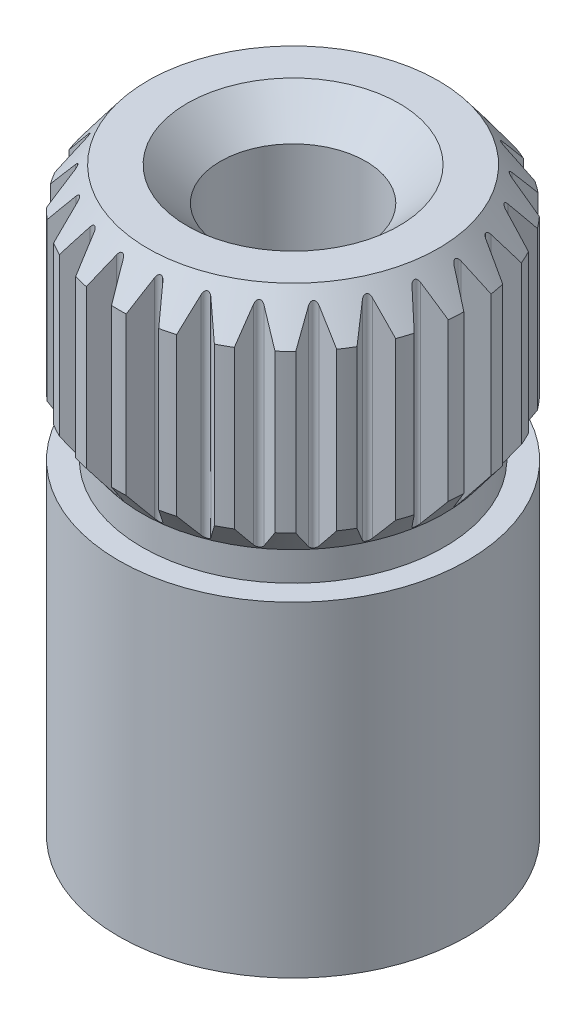
from build123d import *

# Parameters (mm, degrees)
ENL_V_MAT_EXTRU_2_REACH      = 12.863
R_P_TITION_CIRCULAIRE2_COUNT = 25
TROU_TARAUD_M31_D            = 2.5
TROU_TARAUD_M31_DEPTH        = 9
TROU_TARAUD_M31_TIP          = 0.751075774


with BuildPart() as part:
    # Esquisse5 → Révolution1 (revolve)
    with BuildSketch(Plane.XY):
        Polygon((-2.5, 44.2), (0, 44.2), (0, 34.2), (-3, 34.2), (-3, 39.8), (-2.6, 39.8), (-2.6, 40.3), (-3, 40.830817929), (-3, 43.536477589), align=None)
    revolve(axis=Axis((0, 0, 0), (0, 1, 0)))

    # Esquisse3 → Enlèv. mat.-Extru.2 (cut, up to next)
    with BuildSketch(Plane(origin=(0, 44.2, 0), x_dir=(1, 0, 0), z_dir=(0, 1, 0)), mode=Mode.PRIVATE) as enl_v_mat_extru_2_sk1:
        with BuildLine():
            Line((0.25, 2.989565186), (0.063607415, 2.666723758))
            ThreePointArc((0.063607415, 2.666723758), (0, 2.63), (-0.063607415, 2.666723758))
            Line((-0.063607415, 2.666723758), (-0.25, 2.989565186))
            ThreePointArc((-0.25, 2.989565186), (0, 3), (0.25, 2.989565186))
        make_face()
    enl_v_mat_extru_2_tool1 = extrude(enl_v_mat_extru_2_sk1.sketch, amount=-ENL_V_MAT_EXTRU_2_REACH, mode=Mode.PRIVATE) & part.part
    enl_v_mat_extru_2 = enl_v_mat_extru_2_tool1.solids().sort_by_distance((0, 44.2, -2.858035))[0]
    add(enl_v_mat_extru_2, mode=Mode.SUBTRACT)

    # Répétition circulaire2: Enlèv. mat.-Extru.2 ×25 about axis
    r_p_tition_circulaire2_axis = Axis((0, 0, 0), (0, 1, 0))
    for i in range(1, R_P_TITION_CIRCULAIRE2_COUNT):
        add(enl_v_mat_extru_2.rotate(r_p_tition_circulaire2_axis, i * 360 / R_P_TITION_CIRCULAIRE2_COUNT), mode=Mode.SUBTRACT)

    # Trou taraudé M31
    with Locations(Plane(origin=(0, 44.2, 0), x_dir=(1, 0, 0), z_dir=(0, 1, 0))):
        with Locations((0, 0)):
            Hole(TROU_TARAUD_M31_D / 2, depth=TROU_TARAUD_M31_DEPTH)
            with Locations((0, 0, -(TROU_TARAUD_M31_DEPTH + TROU_TARAUD_M31_TIP / 2))):  # 118° drill point
                Cone(0, TROU_TARAUD_M31_D / 2, TROU_TARAUD_M31_TIP, mode=Mode.SUBTRACT)

    # Esquisse9 → Enlèvement de matière-Révolution1 (revolve, cut)
    with BuildSketch(Plane.XY):
        Polygon((1.825, 44.2), (0, 42.375), (0, 44.2), align=None)
    revolve(axis=Axis((0, 45.023690252, 0), (0, -1, 0)), mode=Mode.SUBTRACT)


solid = part.part
